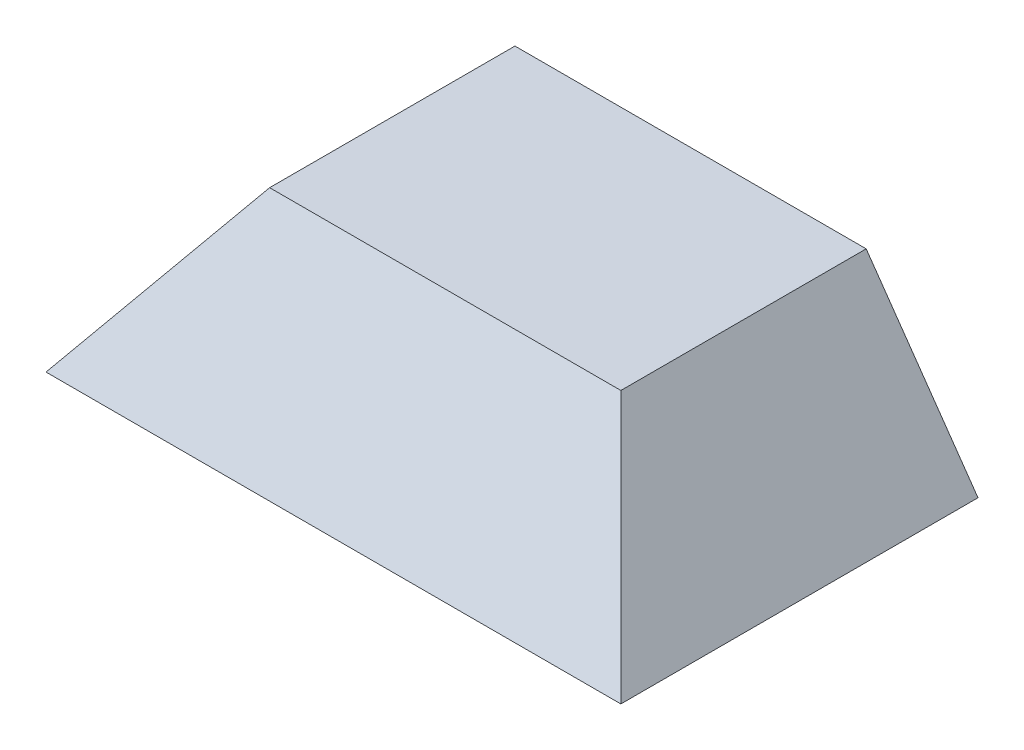
from build123d import *

# Parameters (mm, degrees)
CROQUIS1_W                  = 180
CROQUIS1_H                  = 129.33
SALIENTE_EXTRUIR1_DEPTH     = 50
CORTAR_EXTRUIR1_REACH       = 167.307
CORTAR_EXTRUIR2_REACH       = 199.691
VACIADO1_T                  = -4
SALIENTE_EXTRUIR4_DEPTH     = 102.58126129
CORTAR_EXTRUIR10_DEPTH      = 92.58126129
CROQUIS15_W                 = 55.421449745
CROQUIS15_H                 = 50
CORTAR_EXTRUIR11_DEPTH      = 146.33724632
CORTAR_EXTRUIR11_DEPTH_BACK = 146.33724632
SALIENTE_EXTRUIR6_REACH     = 181.671
CROQUIS19_W                 = 20
CROQUIS19_H                 = 20
CROQUIS20_W                 = 20
CROQUIS20_H                 = 5
CORTAR_EXTRUIR14_DEPTH      = 8
CORTAR_EXTRUIR15_REACH      = 121.61
CROQUIS22_R                 = 1.585


with BuildPart() as part:
    # Croquis1 → Saliente-Extruir1 (new body)
    with BuildSketch(Plane(origin=(0, 0, 0), x_dir=(1, 0, 0), z_dir=(0, 1, 0))):
        Rectangle(CROQUIS1_W, CROQUIS1_H)
    extrude(amount=SALIENTE_EXTRUIR1_DEPTH)

    # Croquis2 → Cortar-Extruir1 (cut, up to next)
    with BuildSketch(Plane.XY.offset(64.665), mode=Mode.PRIVATE) as cortar_extruir1_sk1:
        Polygon((90, 0), (54.98962309, 50), (90, 50), align=None)
    cortar_extruir1_tool1 = extrude(cortar_extruir1_sk1.sketch, amount=-CORTAR_EXTRUIR1_REACH, mode=Mode.PRIVATE) & part.part
    cortar_extruir1 = cortar_extruir1_tool1.solids().sort_by_distance((78.329874, 33.333333, 64.665))[0]
    add(cortar_extruir1, mode=Mode.SUBTRACT)

    # Cortar-Extruir2: up to this plane
    cortar_extruir2_end = Plane(origin=(90, 0, -64.666), z_dir=(-0.819152044288995, -0.5735764363510416, 0))
    # Croquis4 → Cortar-Extruir2 (cut, up to the surface)
    with BuildSketch(Plane.ZY.offset(90), mode=Mode.PRIVATE) as cortar_extruir2_sk1:
        Polygon((-64.665, 0), (-29.65462309, 50), (-64.665, 50), align=None)
    cortar_extruir2_tool1 = split(extrude(cortar_extruir2_sk1.sketch, amount=-CORTAR_EXTRUIR2_REACH, mode=Mode.PRIVATE), bisect_by=cortar_extruir2_end, keep=Keep.BOTH, mode=Mode.PRIVATE)
    cortar_extruir2 = cortar_extruir2_tool1.solids().sort_by_distance((-90, 33.333333, -52.994874))[0]
    add(cortar_extruir2, mode=Mode.SUBTRACT)

    # Simetría2: Cortar-Extruir2 across plane
    add(cortar_extruir2.mirror(Plane.XY), mode=Mode.SUBTRACT)

    # Simetría1: Cortar-Extruir1 across plane
    add(cortar_extruir1.mirror(Plane(origin=(0, 0, 0), x_dir=(0, 0, 1), z_dir=(1, 0, 0))), mode=Mode.SUBTRACT)

    # Simetría1 at the second plane: Cortar-Extruir1 across plane
    add(cortar_extruir1.mirror(Plane.XY), mode=Mode.SUBTRACT)

    # Vaciado1
    vaciado1_openings = [part.faces().sort_by_distance(p)[0] for p in [
        (0, 0, 0),
    ]]
    offset(amount=VACIADO1_T, openings=vaciado1_openings, kind=Kind.INTERSECTION)

    # Croquis7 → Saliente-Extruir4 (add)
    with BuildSketch(Plane(origin=(0, 14.764441718, 0), x_dir=(-1, 0, 0), z_dir=(0, 0, -1))):
        Polygon((-54.98962309, 10.235558282), (-72.494811545, 10.235558282), (-54.98962309, 35.235558282), (54.98962309, 35.235558282), (72.494811545, 10.235558282), (54.98962309, 10.235558282), align=None)
    extrude(amount=SALIENTE_EXTRUIR4_DEPTH)

    # Croquis14 → Cortar-Extruir10 (cut)
    with BuildSketch(Plane.XY):
        Polygon((-85.116901645, 0), (-52.87991258, 46.039191676), (52.934417466, 46.039191676), (85.116901645, 0), align=None)
    extrude(amount=-CORTAR_EXTRUIR10_DEPTH, mode=Mode.SUBTRACT)

    # Croquis15 → Cortar-Extruir11 (cut, two sides)
    with BuildSketch(Plane(origin=(0, 0, 0), x_dir=(0, 0, -1), z_dir=(1, 0, 0))) as cortar_extruir11_sk:
        with Locations((74.870536418, 25)):
            Rectangle(CROQUIS15_W, CROQUIS15_H)
    extrude(amount=CORTAR_EXTRUIR11_DEPTH, mode=Mode.SUBTRACT)
    extrude(cortar_extruir11_sk.sketch, amount=-CORTAR_EXTRUIR11_DEPTH_BACK, mode=Mode.SUBTRACT)

    # Croquis19 → Saliente-Extruir6 (add, up to next)
    with BuildSketch(Plane(origin=(70, 0, 0), x_dir=(0, 0, -1), z_dir=(1, 0, 0)), mode=Mode.PRIVATE) as saliente_extruir6_sk1:
        with Locations((-1.703719293, 10)):
            Rectangle(CROQUIS19_W, CROQUIS19_H)
    saliente_extruir6_tool1 = extrude(saliente_extruir6_sk1.sketch, amount=SALIENTE_EXTRUIR6_REACH, mode=Mode.PRIVATE) - part.part
    saliente_extruir6 = saliente_extruir6_tool1.solids().sort_by_distance((70, 10, 1.703719))[0]
    add(saliente_extruir6)

    # Croquis20 → Cortar-Extruir14 (cut)
    with BuildSketch(Plane.ZY.offset(-70)):
        with Locations((1.703719293, 7.5)):
            Rectangle(CROQUIS20_W, CROQUIS20_H)
    cortar_extruir14 = extrude(amount=-CORTAR_EXTRUIR14_DEPTH, mode=Mode.SUBTRACT)

    # Croquis22 → Cortar-Extruir15 (cut, up to next)
    with BuildSketch(Plane(origin=(0, 5, 0), x_dir=(1, 0, 0), z_dir=(0, 1, 0)), mode=Mode.PRIVATE) as cortar_extruir15_sk1:
        with Locations(Location((74, -1.703719293, 0), (0, 0, 270))):
            Circle(CROQUIS22_R)
    cortar_extruir15_tool1 = extrude(cortar_extruir15_sk1.sketch, amount=-CORTAR_EXTRUIR15_REACH, mode=Mode.PRIVATE) & part.part
    cortar_extruir15 = cortar_extruir15_tool1.solids().sort_by_distance((74, 5, 1.703719))[0]
    add(cortar_extruir15, mode=Mode.SUBTRACT)

    # Simetría3: Saliente-Extruir6, Cortar-Extruir14, Cortar-Extruir15 across plane
    add(saliente_extruir6.mirror(Plane(origin=(0, 0, 0), x_dir=(0, 0, 1), z_dir=(1, 0, 0))))
    add(cortar_extruir14.mirror(Plane(origin=(0, 0, 0), x_dir=(0, 0, 1), z_dir=(1, 0, 0))), mode=Mode.SUBTRACT)
    add(cortar_extruir15.mirror(Plane(origin=(0, 0, 0), x_dir=(0, 0, 1), z_dir=(1, 0, 0))), mode=Mode.SUBTRACT)


solid = part.part
